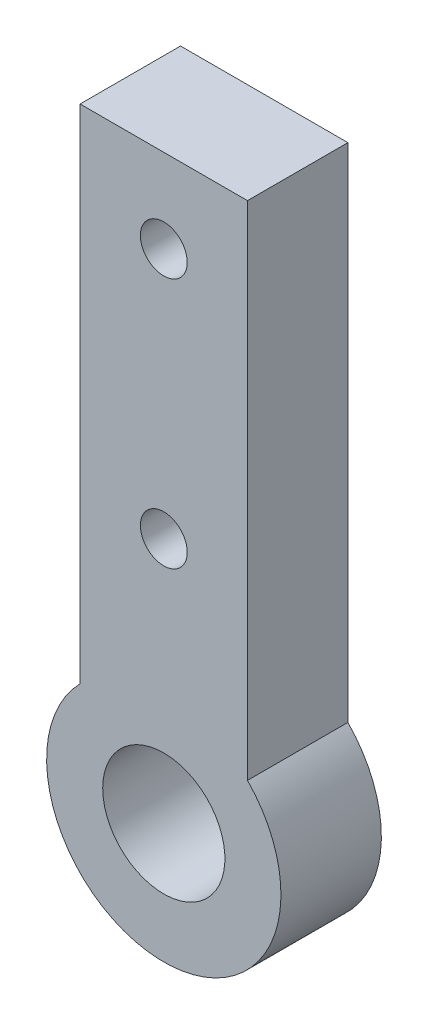
from build123d import *

# Parameters (mm, degrees)
BOSS_EXTRU_1_DEPTH      = 6
ESQUISSE2_R             = 3.65
ESQUISSE2_R_2           = 1.4
ENL_V_MAT_EXTRU_1_DEPTH = 6


with BuildPart() as part:
    # Esquisse1 → Boss.-Extru.1 (new body)
    with BuildSketch(Plane.XY):
        with BuildLine():
            Line((-5, 18.927916642), (5, 18.927916642))
            Line((5, 18.927916642), (5, -11.072083358))
            ThreePointArc((5, -11.072083358), (0, -22.971062844), (-5, -11.072083358))
            Line((-5, -11.072083358), (-5, 18.927916642))
        make_face()
    extrude(amount=BOSS_EXTRU_1_DEPTH)

    # Esquisse2 → Enlèv. mat.-Extru.1 (cut)
    with BuildSketch(Plane(origin=(0, 0, 0), x_dir=(-1, 0, 0), z_dir=(0, 0, -1))):
        with Locations((0, -15.799586654)):
            Circle(ESQUISSE2_R)
        with Locations((0, -1.072083358)):
            Circle(ESQUISSE2_R_2)
        with Locations((0, 13.927916642)):
            Circle(ESQUISSE2_R_2)
    extrude(amount=-ENL_V_MAT_EXTRU_1_DEPTH, mode=Mode.SUBTRACT)


solid = part.part
